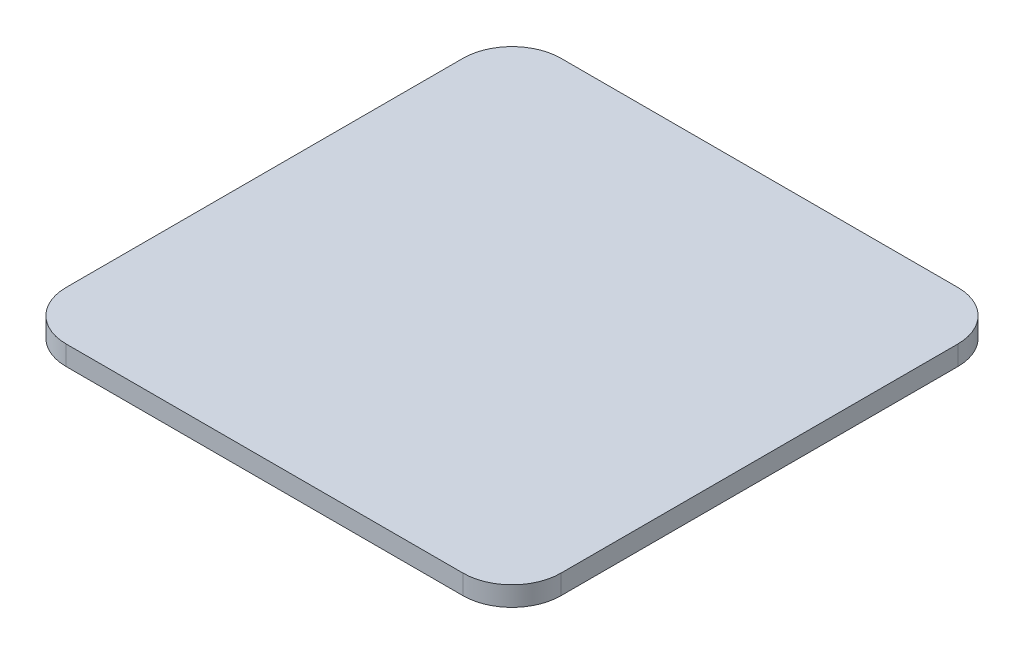
from build123d import *

# Parameters (mm, degrees)
EXTRUDE_1_DEPTH = 2


with BuildPart() as part:
    # 草图1 → 凸台-拉伸1 (new body)
    with BuildSketch(Plane(origin=(0, 0, 0), x_dir=(1, 0, 0), z_dir=(0, 1, 0))):
        with BuildLine():
            Line((-20.25, 25.25), (20.25, 25.25))
            ThreePointArc((20.25, 25.25), (23.785533906, 23.785533906), (25.25, 20.25))
            Line((25.25, 20.25), (25.25, -20.25))
            ThreePointArc((25.25, -20.25), (23.785533906, -23.785533906), (20.25, -25.25))
            Line((20.25, -25.25), (-20.25, -25.25))
            ThreePointArc((-20.25, -25.25), (-23.785533906, -23.785533906), (-25.25, -20.25))
            Line((-25.25, -20.25), (-25.25, 20.25))
            ThreePointArc((-25.25, 20.25), (-23.785533906, 23.785533906), (-20.25, 25.25))
        make_face()
    extrude(amount=EXTRUDE_1_DEPTH)


solid = part.part
